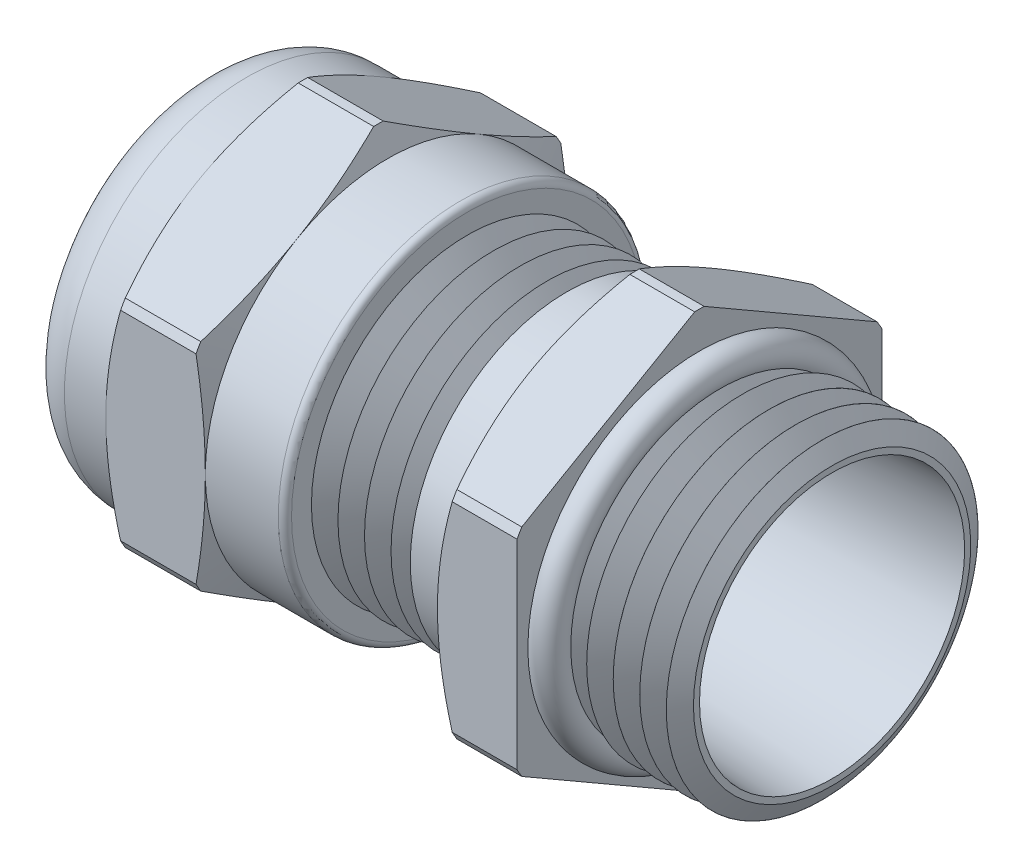
from build123d import *

# Parameters (mm, degrees)
SKETCH6_OUTSIDE_W  = 24.528
SKETCH6_OUTSIDE_H  = 24.528
CUT_EXTRUDE2_DEPTH = 15.748
SKETCH7_OUTSIDE_W  = 31.19
SKETCH7_OUTSIDE_H  = 33.146
SKETCH7_OUTSIDE_R  = 6.985
CUT_EXTRUDE3_DEPTH = 2.54
CUT_EXTRUDE3_DRAFT = -60
SKETCH8_OUTSIDE_W  = 36.35
SKETCH8_OUTSIDE_H  = 38.306
SKETCH8_OUTSIDE_R  = 6.985
CUT_EXTRUDE4_DEPTH = 2.54
CUT_EXTRUDE4_DRAFT = -70
SKETCH9_OUTSIDE_W  = 54.012
SKETCH9_OUTSIDE_H  = 55.968
SKETCH9_OUTSIDE_R  = 6.985
CUT_EXTRUDE5_DEPTH = 9.128
CUT_EXTRUDE5_DRAFT = -60
FILLET1_R          = 1.7145
LPATTERN1_COUNT    = 6
LPATTERN1_PITCH    = 1.016
LPATTERN2_COUNT    = 5
LPATTERN2_PITCH    = 1.016
SKETCH16_R         = 5.9944
SKETCH16_R_2       = 5.077299857
EXTRUDE4_DEPTH     = 2.032
FILLET5_R          = 0.254
SKETCH18_R         = 0.635


with BuildPart() as part:
    # Sketch2 → Revolve1 (revolve)
    with BuildSketch(Plane.XY, mode=Mode.PRIVATE) as revolve1_sk:
        Polygon((-12.065, 5.064125), (-12.065, 6.985), (-8.763, 6.985), (-8.763, 7.9629), (-4.953, 7.9629), (-4.953, 6.985), (-1.905, 6.985), (-1.905, 5.969), (3.937, 5.969), (3.937, 7.9629), (6.985, 7.9629), (6.985, 5.969), (12.065, 5.968911337), (12.065, 5.077299857), (0, 4.445), (-8.763, 4.445), (-8.763, 5.064125), align=None)
    revolve(revolve1_sk.sketch.rotate(Axis((-69.075133251, 0, 0), (1, 0, 0)), 90), axis=Axis((-69.075133251, 0, 0), (1, 0, 0)))  # turned: the seam where the file's is

    # Sketch6 outside → Cut-Extrude2 (cut)
    with BuildSketch(Plane(origin=(6.985, 0, 0), x_dir=(0, 0, -1), z_dir=(1, 0, 0))):
        Rectangle(SKETCH6_OUTSIDE_W, SKETCH6_OUTSIDE_H)
        with BuildLine():
            Line((6.985, -3.823290652), (6.985, 3.823290652))
            ThreePointArc((6.985, 3.823290652), (6.896073688, 3.98145), (6.803566831, 4.137542119))
            Line((6.803566831, 4.137542119), (0.181433169, 7.960832771))
            ThreePointArc((0.181433169, 7.960832771), (0, 7.9629), (-0.181433169, 7.960832771))
            Line((-0.181433169, 7.960832771), (-6.803566831, 4.137542119))
            ThreePointArc((-6.803566831, 4.137542119), (-6.896073688, 3.98145), (-6.985, 3.823290652))
            Line((-6.985, 3.823290652), (-6.985, -3.823290652))
            ThreePointArc((-6.985, -3.823290652), (-6.896073688, -3.98145), (-6.803566831, -4.137542119))
            Line((-6.803566831, -4.137542119), (-0.181433169, -7.960832771))
            ThreePointArc((-0.181433169, -7.960832771), (0, -7.9629), (0.181433169, -7.960832771))
            Line((0.181433169, -7.960832771), (6.803566831, -4.137542119))
            ThreePointArc((6.803566831, -4.137542119), (6.896073688, -3.98145), (6.985, -3.823290652))
        make_face(mode=Mode.SUBTRACT)
    extrude(amount=-CUT_EXTRUDE2_DEPTH, mode=Mode.SUBTRACT)


with BuildPart() as cut_extrude3_tool:
    # Sketch7 outside → Cut-Extrude3 (with draft: the straight prism first)
    with BuildSketch(Plane.ZY.offset(8.763)):
        Rectangle(SKETCH7_OUTSIDE_W, SKETCH7_OUTSIDE_H)
        Circle(SKETCH7_OUTSIDE_R, mode=Mode.SUBTRACT)
    extrude(amount=-CUT_EXTRUDE3_DEPTH)
    # Cut-Extrude3: the draft: its side faces are tilted about the plane it starts from
    cut_extrude3_sides = [cut_extrude3_tool.faces().sort_by_distance(p)[0] for p in [
        (-7.493, -16.573, 0),
        (-7.493, 0, 15.595),
        (-7.493, 16.573, 0),
        (-7.493, 0, -15.595),
        (-7.493, 0, -6.985),
    ]]
    draft(cut_extrude3_sides, Plane.ZY.offset(8.763), CUT_EXTRUDE3_DRAFT)


with BuildPart() as part_1:
    add(part.part)

    # Cut-Extrude3: cut by cut_extrude3_tool
    add(cut_extrude3_tool.part, mode=Mode.SUBTRACT)


with BuildPart() as cut_extrude4_tool:
    # Sketch8 outside → Cut-Extrude4 (with draft: the straight prism first)
    with BuildSketch(Plane(origin=(-4.953, 0, 0), x_dir=(0, 0, -1), z_dir=(1, 0, 0))):
        Rectangle(SKETCH8_OUTSIDE_W, SKETCH8_OUTSIDE_H)
        with Locations(Location((0, 0, 0), (0, 0, 180))):  # turned: the seam where the file's is
            Circle(SKETCH8_OUTSIDE_R, mode=Mode.SUBTRACT)
    extrude(amount=-CUT_EXTRUDE4_DEPTH)
    # Cut-Extrude4: the draft: its side faces are tilted about the plane it starts from
    cut_extrude4_sides = [cut_extrude4_tool.faces().sort_by_distance(p)[0] for p in [
        (-6.223, -19.153, 0),
        (-6.223, 0, -18.175),
        (-6.223, 19.153, 0),
        (-6.223, 0, 18.175),
        (-6.223, 0, -6.985),
    ]]
    draft(cut_extrude4_sides, Plane(origin=(-4.953, 0, 0), x_dir=(0, 0, -1), z_dir=(1, 0, 0)), CUT_EXTRUDE4_DRAFT)


with BuildPart() as part_2:
    add(part_1.part)

    # Cut-Extrude4: cut by cut_extrude4_tool
    add(cut_extrude4_tool.part, mode=Mode.SUBTRACT)


with BuildPart() as cut_extrude5_tool:
    # Sketch9 outside → Cut-Extrude5 (with draft: the straight prism first)
    with BuildSketch(Plane.ZY.offset(-3.937)):
        Rectangle(SKETCH9_OUTSIDE_W, SKETCH9_OUTSIDE_H)
        Circle(SKETCH9_OUTSIDE_R, mode=Mode.SUBTRACT)
    extrude(amount=-CUT_EXTRUDE5_DEPTH)
    # Cut-Extrude5: the draft: its side faces are tilted about the plane it starts from
    cut_extrude5_sides = [cut_extrude5_tool.faces().sort_by_distance(p)[0] for p in [
        (8.501, -27.984, 0),
        (8.501, 0, 27.006),
        (8.501, 27.984, 0),
        (8.501, 0, -27.006),
        (8.501, 0, -6.985),
    ]]
    draft(cut_extrude5_sides, Plane.ZY.offset(-3.937), CUT_EXTRUDE5_DRAFT)


with BuildPart() as part_3:
    add(part_2.part)

    # Cut-Extrude5: cut by cut_extrude5_tool
    add(cut_extrude5_tool.part, mode=Mode.SUBTRACT)

    # Fillet1
    fillet1_edges = [part_3.edges().sort_by_distance(p)[0] for p in [
        (-12.065, 0, -6.985),
    ]]
    fillet(fillet1_edges, radius=FILLET1_R)

    # Sketch13 → Cut-Revolve1 (revolve, cut)
    with BuildSketch(Plane.XY, mode=Mode.PRIVATE) as cut_revolve1_sk:
        Polygon((-1.905, 5.969), (-0.889, 5.969), (-1.397, 5.08911819), align=None)
    cut_revolve1 = revolve(cut_revolve1_sk.sketch.rotate(Axis((-15.434011776, 0, 0), (1, 0, 0)), 90), axis=Axis((-15.434011776, 0, 0), (1, 0, 0)), mode=Mode.SUBTRACT)  # turned: the seam where the file's is

    # LPattern1: Cut-Revolve1 ×6
    with Locations(*[(i * LPATTERN1_PITCH, 0, 0) for i in range(1, LPATTERN1_COUNT)]):
        add(cut_revolve1, mode=Mode.SUBTRACT)

    # Sketch14 → Cut-Revolve2 (revolve, cut)
    with BuildSketch(Plane.XY, mode=Mode.PRIVATE) as cut_revolve2_sk:
        Polygon((7.62, 5.968988917), (8.636, 5.968971185), (8.127984643, 5.089098241), align=None)
    cut_revolve2 = revolve(cut_revolve2_sk.sketch.rotate(Axis((-13.79514925, 0, 0), (1, 0, 0)), 90), axis=Axis((-13.79514925, 0, 0), (1, 0, 0)), mode=Mode.SUBTRACT)  # turned: the seam where the file's is

    # LPattern2: Cut-Revolve2 ×5
    with Locations(*[(i * LPATTERN2_PITCH, 0, 0) for i in range(1, LPATTERN2_COUNT)]):
        add(cut_revolve2, mode=Mode.SUBTRACT)

    # Sketch16 → Extrude4 (add)
    with BuildSketch(Plane.ZY.offset(-3.937)):
        with Locations(Location((0, 0, 0), (0, 0, 180))):  # turned: the seam where the file's is
            Circle(SKETCH16_R)
        Circle(SKETCH16_R_2, mode=Mode.SUBTRACT)
    extrude(amount=EXTRUDE4_DEPTH)

    # Fillet5
    fillet5_edges = [part_3.edges().sort_by_distance(p)[0] for p in [
        (-1.905, 0, -6.985),
    ]]
    fillet(fillet5_edges, radius=FILLET5_R)

    # Sketch18 → Revolve4 (revolve)
    with BuildSketch(Plane.XY, mode=Mode.PRIVATE) as revolve4_sk:
        with Locations((7.1882, 5.968996453)):
            Circle(SKETCH18_R)
    revolve(revolve4_sk.sketch.rotate(Axis((19.121197091, 0, 0), (-1, 0, 0)), 270), axis=Axis((19.121197091, 0, 0), (-1, 0, 0)))  # turned: the seam where the file's is


with BuildPart() as body_2:
    # Sketch12 → Revolve3 (revolve)
    with BuildSketch(Plane.XY, mode=Mode.PRIVATE) as revolve3_sk:
        with BuildLine():
            Line((-8.763, 4.445), (-8.763, 5.064125))
            Line((-8.763, 5.064125), (-11.303, 5.064125))
            ThreePointArc((-11.303, 5.064125), (-11.482605122, 4.989730122), (-11.557, 4.810125))
            Line((-11.557, 4.810125), (-11.557, 4.445))
            Line((-11.557, 4.445), (-8.763, 4.445))
        make_face()
    revolve(revolve3_sk.sketch.rotate(Axis((13.84956521, 0, 0), (-1, 0, 0)), 270), axis=Axis((13.84956521, 0, 0), (-1, 0, 0)))  # turned: the seam where the file's is


solid = Compound([part_3.part, body_2.part])
